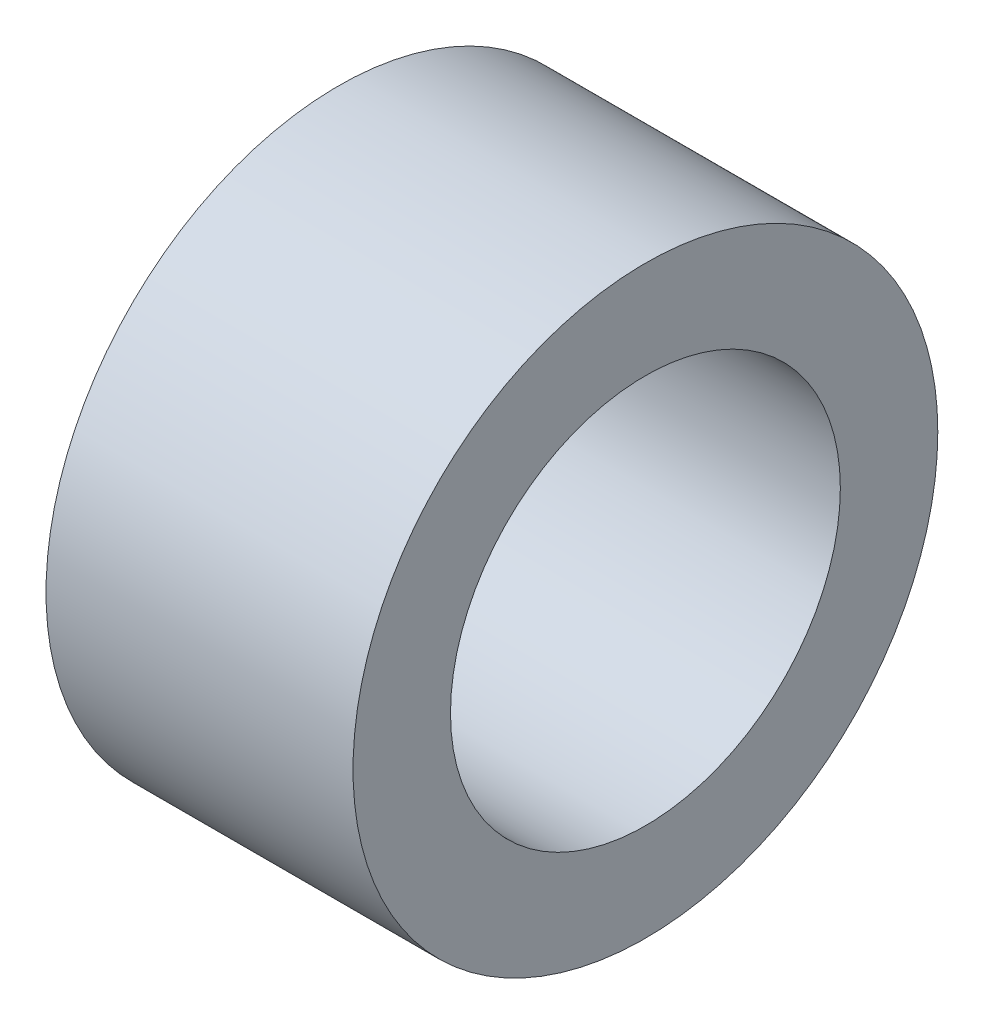
from build123d import *

# Parameters (mm, degrees)
BOSS_EXTRUDE1_DEPTH      = 6.3
BOSS_EXTRUDE1_DEPTH_BACK = 6.3
SKETCH1_R                = 12
SKETCH1_R_2              = 8


with BuildPart() as part:
    # Sketch1 → Boss-Extrude1 (new, two sides: drawn at the far end of the back side and taken through both)
    with BuildSketch(Plane(origin=(0, 0, 0), x_dir=(0, 0, -1), z_dir=(1, 0, 0)).offset(-BOSS_EXTRUDE1_DEPTH_BACK)):
        with Locations((-19.07707261, 3.561053554)):
            Circle(SKETCH1_R)
        with Locations((-19.07707261, 3.561053554)):
            Circle(SKETCH1_R_2, mode=Mode.SUBTRACT)
    extrude(amount=BOSS_EXTRUDE1_DEPTH + BOSS_EXTRUDE1_DEPTH_BACK)


solid = part.part
